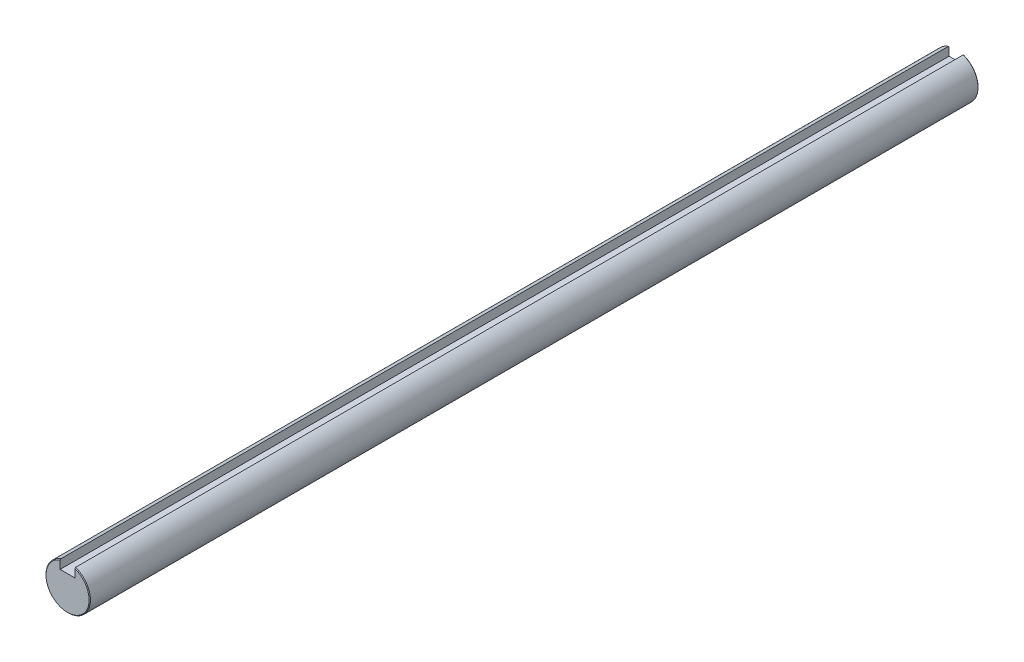
from build123d import *

# Parameters (mm, degrees)
BOSS_EXTRUDE1_DEPTH      = 150
BOSS_EXTRUDE1_DEPTH_BACK = 150
CHAMFER1_SIZE            = 0.225


with BuildPart() as part:
    # Sketch3 → Boss-Extrude1 (new body, two sides)
    with BuildSketch(Plane.XY) as boss_extrude1_sk:
        with BuildLine():
            Line((-2.5, 4.071067812), (-2.5, 7.071067812))
            ThreePointArc((-2.5, 7.071067812), (0, -7.5), (2.5, 7.071067812))
            Line((2.5, 7.071067812), (2.5, 4.071067812))
            Line((2.5, 4.071067812), (-2.5, 4.071067812))
        make_face()
    extrude(amount=BOSS_EXTRUDE1_DEPTH)
    extrude(boss_extrude1_sk.sketch, amount=-BOSS_EXTRUDE1_DEPTH_BACK)

    # Chamfer1
    chamfer1_edges = [part.edges().sort_by_distance(p)[0] for p in [
        (0, -7.5, -150),
        (0, -7.5, 150),
    ]]
    chamfer(chamfer1_edges, length=CHAMFER1_SIZE)


solid = part.part
